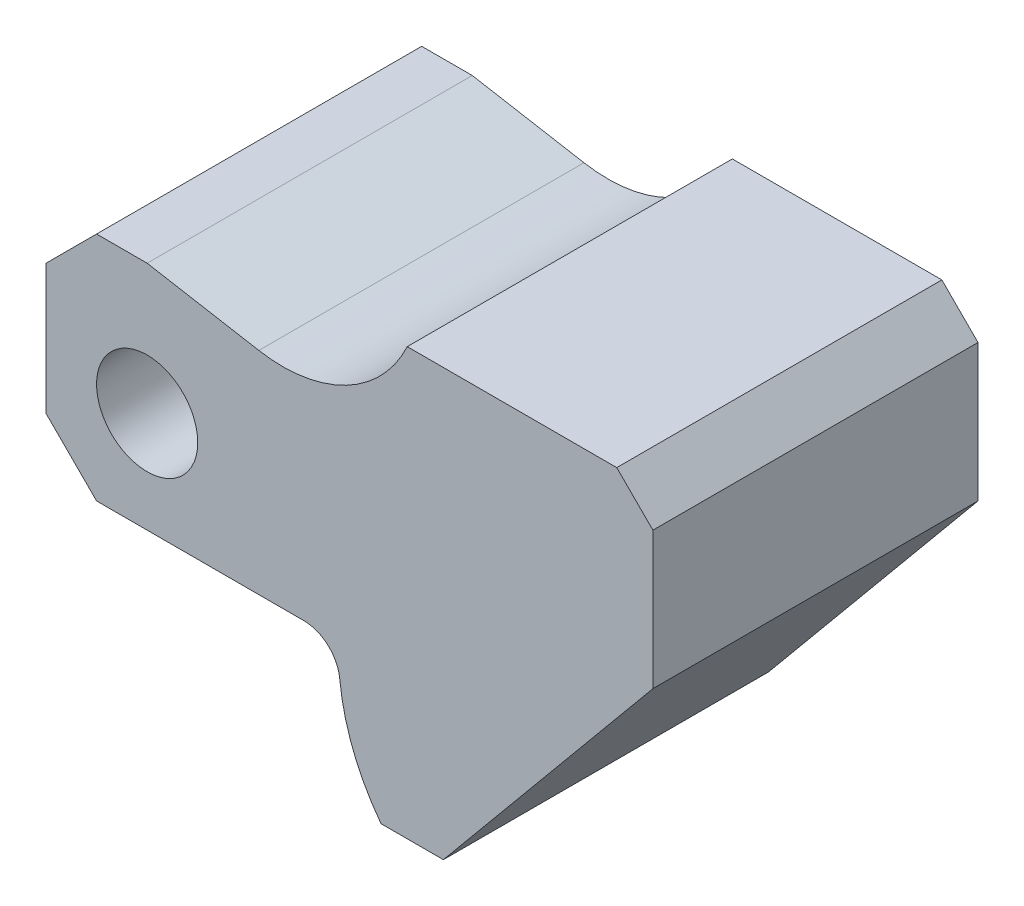
from build123d import *

# Parameters (mm, degrees)
SKETCH2_R           = 7
BOSS_EXTRUDE1_DEPTH = 45


with BuildPart() as part:
    # Sketch2 → Boss-Extrude1 (new body)
    with BuildSketch(Plane.XY):
        with BuildLine():
            Line((-14, 11), (-14, -7))
            Line((-14, -7), (-7, -14))
            Line((-7, -14), (21.680626854, -14))
            ThreePointArc((21.680626854, -14), (25.029243776, -15.286946714), (26.654064081, -18.485294118))
            ThreePointArc((26.654064081, -18.485294118), (28.520286549, -26.134616219), (32.37533784, -33))
            Line((32.37533784, -33), (41, -33))
            Line((41, -33), (70, 2))
            Line((70, 2), (70, 21))
            Line((70, 21), (65, 26))
            Line((65, 26), (36, 26))
            ThreePointArc((36, 26), (27.554449431, 17.143424137), (15.460180615, 15.273953031))
            Line((15.460180615, 15.273953031), (0, 18))
            Line((0, 18), (-7, 18))
            Line((-7, 18), (-14, 11))
        make_face()
        Circle(SKETCH2_R, mode=Mode.SUBTRACT)
    extrude(amount=BOSS_EXTRUDE1_DEPTH)


solid = part.part
